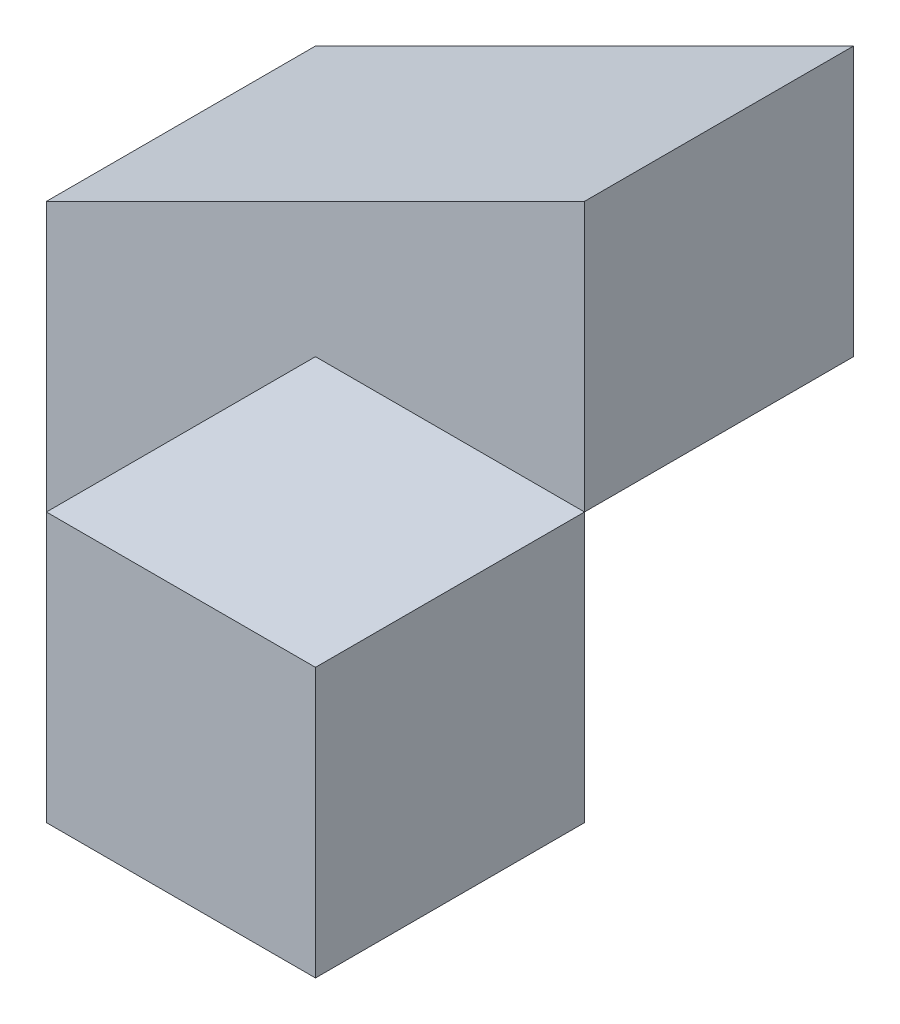
from build123d import *

# Parameters (mm, degrees)
SKETCH1_W           = 40
SKETCH1_H           = 40
BOSS_EXTRUDE1_DEPTH = 40
CUT_EXTRUDE1_DEPTH  = 40
SKETCH3_W           = 20
SKETCH3_H           = 20
CUT_EXTRUDE2_DEPTH  = 40
CUT_EXTRUDE3_DEPTH  = 20
SKETCH5_W           = 20
SKETCH5_H           = 20
CUT_EXTRUDE4_DEPTH  = 20


with BuildPart() as part:
    # Sketch1 → Boss-Extrude1 (new body)
    with BuildSketch(Plane.XY):
        with Locations((20, 20)):
            Rectangle(SKETCH1_W, SKETCH1_H)
    extrude(amount=BOSS_EXTRUDE1_DEPTH)

    # Sketch2 → Cut-Extrude1 (cut)
    with BuildSketch(Plane.XY.offset(40)):
        Polygon((40, 40), (0, 20), (0, 40), align=None)
    extrude(amount=-CUT_EXTRUDE1_DEPTH, mode=Mode.SUBTRACT)

    # Sketch3 → Cut-Extrude2 (cut)
    with BuildSketch(Plane(origin=(40, 0, 0), x_dir=(0, 0, -1), z_dir=(1, 0, 0))):
        with Locations((-30, 30)):
            Rectangle(SKETCH3_W, SKETCH3_H)
    extrude(amount=-CUT_EXTRUDE2_DEPTH, mode=Mode.SUBTRACT)

    # Sketch4 → Cut-Extrude3 (cut)
    with BuildSketch(Plane.XZ):
        Polygon((40, 0), (40, 20), (20, 0), align=None)
    extrude(amount=-CUT_EXTRUDE3_DEPTH, mode=Mode.SUBTRACT)

    # Sketch5 → Cut-Extrude4 (cut)
    with BuildSketch(Plane(origin=(0, 20, 0), x_dir=(1, 0, 0), z_dir=(0, 1, 0))):
        with Locations((10, -30)):
            Rectangle(SKETCH5_W, SKETCH5_H)
    extrude(amount=-CUT_EXTRUDE4_DEPTH, mode=Mode.SUBTRACT)


solid = part.part
